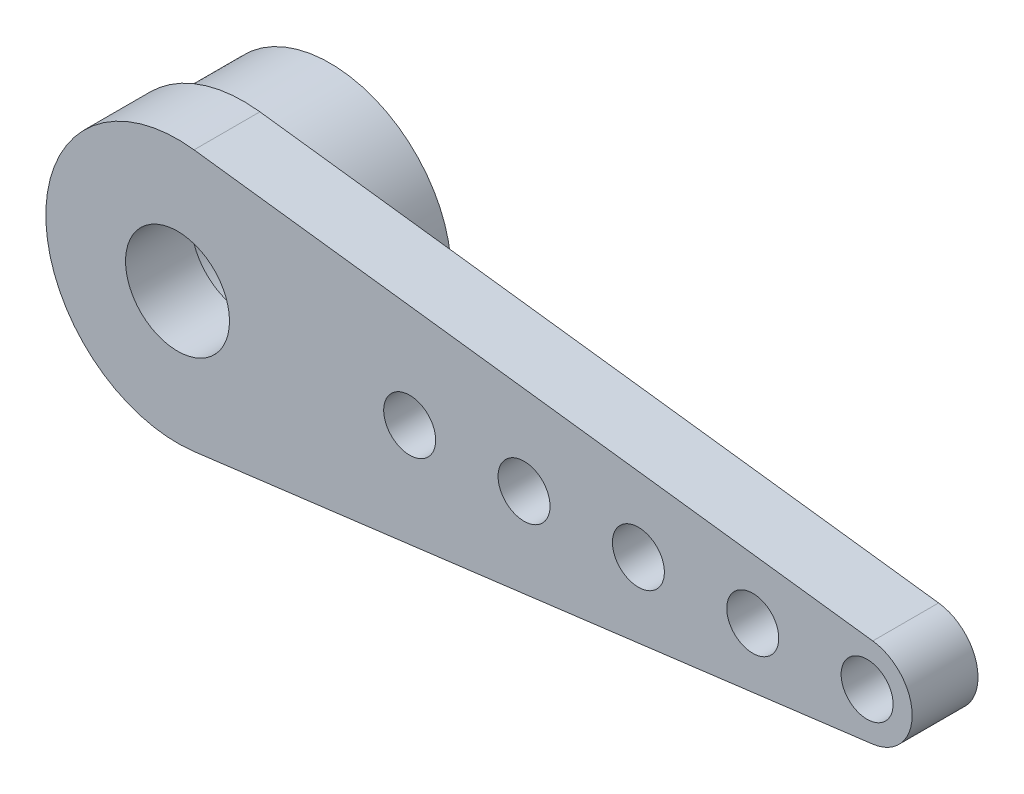
from build123d import *

# Parameters (mm, degrees)
SCHIZZO2_R                   = 0.75
SCHIZZO2_R_2                 = 1.5
ESTRUSIONE_ESTRUSIONE1_DEPTH = 1.9
SCHIZZO3_R                   = 3.5
SCHIZZO3_R_2                 = 2.307795375
ESTRUSIONE_ESTRUSIONE2_DEPTH = 2.5


with BuildPart() as part:
    # Schizzo2 → Estrusione-Estrusione1 (new body)
    with BuildSketch(Plane.XY):
        with BuildLine():
            Line((0.477386935, 3.769894125), (20.063316583, 1.289700622))
            ThreePointArc((20.063316583, 1.289700622), (21.2, 0), (20.063316583, -1.289700622))
            Line((20.063316583, -1.289700622), (0.477386935, -3.769894125))
            ThreePointArc((0.477386935, -3.769894125), (-3.8, 0), (0.477386935, 3.769894125))
        make_face()
        with Locations((19.9, 0)):
            Circle(SCHIZZO2_R, mode=Mode.SUBTRACT)
        with Locations((6.7, 0)):
            Circle(SCHIZZO2_R, mode=Mode.SUBTRACT)
        with Locations((10, 0)):
            Circle(SCHIZZO2_R, mode=Mode.SUBTRACT)
        with Locations((13.3, 0)):
            Circle(SCHIZZO2_R, mode=Mode.SUBTRACT)
        with Locations((16.6, 0)):
            Circle(SCHIZZO2_R, mode=Mode.SUBTRACT)
        Circle(SCHIZZO2_R_2, mode=Mode.SUBTRACT)
    extrude(amount=ESTRUSIONE_ESTRUSIONE1_DEPTH)

    # Schizzo3 → Estrusione-Estrusione2 (add)
    with BuildSketch(Plane.XY):
        Circle(SCHIZZO3_R)
        Circle(SCHIZZO3_R_2, mode=Mode.SUBTRACT)
    extrude(amount=-ESTRUSIONE_ESTRUSIONE2_DEPTH)


solid = part.part
